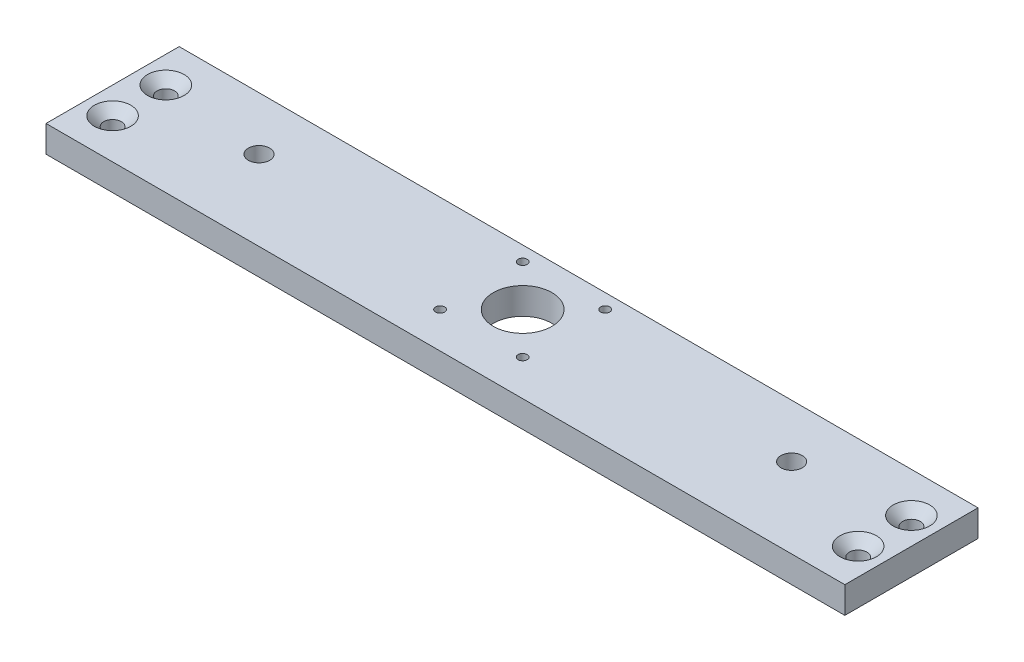
from build123d import *

# Parameters (mm, degrees)
SKETCH1_W                                            = 300
SKETCH1_H                                            = 50
SKETCH1_R                                            = 4
MAIN_DEPTH                                           = 10
SKETCH4_R                                            = 2.5
MOUNT_DEPTH                                          = 11
SKETCH2_R                                            = 11
SKETCH2_R_2                                          = 1.5
STEPPER_MOUNT_DEPTH                                  = 11
CSK_FOR_M6_SOCKET_COUNTERSUNK_HEAD_SCREW_D           = 6.6
CSK_FOR_M6_SOCKET_COUNTERSUNK_HEAD_SCREW_DEPTH       = 15
CSK_FOR_M6_SOCKET_COUNTERSUNK_HEAD_SCREW_CSINK_D     = 13.71
CSK_FOR_M6_SOCKET_COUNTERSUNK_HEAD_SCREW_CSINK_ANGLE = 90
CSK_FOR_M6_SOCKET_COUNTERSUNK_HEAD_SCREW_TIP         = 1.982840043
CSK_FOR_M3_SOCKET_COUNTERSUNK_HEAD_SCREW_D           = 3.4
CSK_FOR_M3_SOCKET_COUNTERSUNK_HEAD_SCREW_DEPTH       = 15
CSK_FOR_M3_SOCKET_COUNTERSUNK_HEAD_SCREW_CSINK_D     = 6.94
CSK_FOR_M3_SOCKET_COUNTERSUNK_HEAD_SCREW_CSINK_ANGLE = 90
CSK_FOR_M3_SOCKET_COUNTERSUNK_HEAD_SCREW_TIP         = 1.021463052


with BuildPart() as part:
    # Sketch1 → main (new body)
    with BuildSketch(Plane(origin=(0, 0, 0), x_dir=(1, 0, 0), z_dir=(0, 1, 0))):
        with Locations((0, -5)):
            Rectangle(SKETCH1_W, SKETCH1_H)
        with Locations((-100, 0)):
            Circle(SKETCH1_R, mode=Mode.SUBTRACT)
        with Locations((100, 0)):
            Circle(SKETCH1_R, mode=Mode.SUBTRACT)
    extrude(amount=MAIN_DEPTH)

    # Sketch4 → mount (cut, through all)
    with BuildSketch(Plane(origin=(0, 10, 0), x_dir=(1, 0, 0), z_dir=(0, 1, 0))):
        with Locations((-140, 5)):
            Circle(SKETCH4_R)
        with Locations((-140, -15)):
            Circle(SKETCH4_R)
        with Locations((140, -15)):
            Circle(SKETCH4_R)
        with Locations((140, 5)):
            Circle(SKETCH4_R)
    extrude(amount=-MOUNT_DEPTH, mode=Mode.SUBTRACT)

    # Sketch2 → stepper_mount (cut, through all)
    with BuildSketch(Plane(origin=(0, 10, 0), x_dir=(1, 0, 0), z_dir=(0, 1, 0))):
        with Locations((0, -1)):
            Circle(SKETCH2_R)
        with Locations((15.5, -16.5)):
            Circle(SKETCH2_R_2)
        with Locations((-15.5, -16.5)):
            Circle(SKETCH2_R_2)
        with Locations((-15.5, 14.5)):
            Circle(SKETCH2_R_2)
        with Locations((15.5, 14.5)):
            Circle(SKETCH2_R_2)
    extrude(amount=-STEPPER_MOUNT_DEPTH, mode=Mode.SUBTRACT)

    # CSK for M6 socket countersunk head screw1
    with Locations(Plane(origin=(0, 10, 0), x_dir=(1, 0, 0), z_dir=(0, 1, 0))):
        with Locations((140, -15), (140, 5), (-140, -15), (-140, 5)):
            CounterSinkHole(CSK_FOR_M6_SOCKET_COUNTERSUNK_HEAD_SCREW_D / 2, CSK_FOR_M6_SOCKET_COUNTERSUNK_HEAD_SCREW_CSINK_D / 2, depth=CSK_FOR_M6_SOCKET_COUNTERSUNK_HEAD_SCREW_DEPTH, counter_sink_angle=CSK_FOR_M6_SOCKET_COUNTERSUNK_HEAD_SCREW_CSINK_ANGLE)
            with Locations((0, 0, -(CSK_FOR_M6_SOCKET_COUNTERSUNK_HEAD_SCREW_DEPTH + CSK_FOR_M6_SOCKET_COUNTERSUNK_HEAD_SCREW_TIP / 2))):  # 118° drill point
                Cone(0, CSK_FOR_M6_SOCKET_COUNTERSUNK_HEAD_SCREW_D / 2, CSK_FOR_M6_SOCKET_COUNTERSUNK_HEAD_SCREW_TIP, mode=Mode.SUBTRACT)

    # CSK for M3 socket countersunk head screw1
    with Locations(Plane(origin=(0, 0, 0), x_dir=(-1, 0, 0), z_dir=(0, -1, 0))):
        with Locations((15.5, -16.5), (-15.5, -16.5), (-15.5, 14.5), (15.5, 14.5)):
            CounterSinkHole(CSK_FOR_M3_SOCKET_COUNTERSUNK_HEAD_SCREW_D / 2, CSK_FOR_M3_SOCKET_COUNTERSUNK_HEAD_SCREW_CSINK_D / 2, depth=CSK_FOR_M3_SOCKET_COUNTERSUNK_HEAD_SCREW_DEPTH, counter_sink_angle=CSK_FOR_M3_SOCKET_COUNTERSUNK_HEAD_SCREW_CSINK_ANGLE)
            with Locations((0, 0, -(CSK_FOR_M3_SOCKET_COUNTERSUNK_HEAD_SCREW_DEPTH + CSK_FOR_M3_SOCKET_COUNTERSUNK_HEAD_SCREW_TIP / 2))):  # 118° drill point
                Cone(0, CSK_FOR_M3_SOCKET_COUNTERSUNK_HEAD_SCREW_D / 2, CSK_FOR_M3_SOCKET_COUNTERSUNK_HEAD_SCREW_TIP, mode=Mode.SUBTRACT)


solid = part.part
